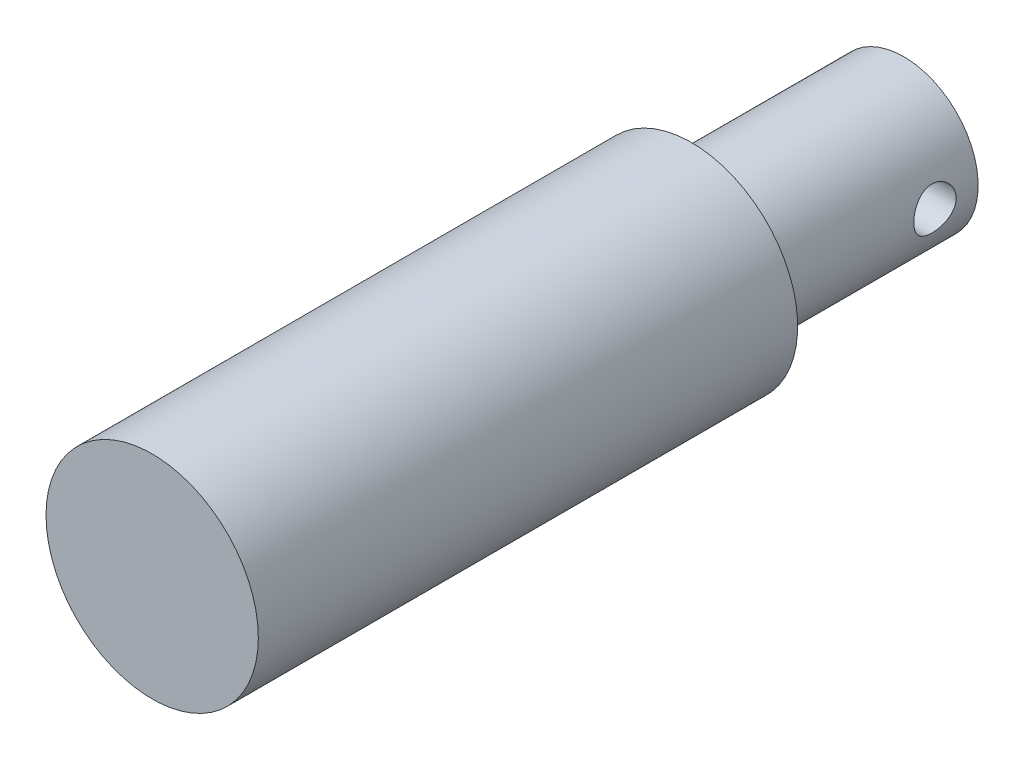
from build123d import *

# Parameters (mm, degrees)
SKETCH1_R               = 5
BOSS_EXTRUDE1_DEPTH     = 35.4
SKETCH2_R               = 1
CUT_EXTRUDE1_DEPTH      = 6
CUT_EXTRUDE1_DEPTH_BACK = 6
SKETCH3_OUTSIDE_W       = 19.624
SKETCH3_OUTSIDE_H       = 19.624
SKETCH3_OUTSIDE_R       = 3.5
CUT_EXTRUDE2_DEPTH      = 10


with BuildPart() as part:
    # Sketch1 → Boss-Extrude1 (new body)
    with BuildSketch(Plane.XY):
        Circle(SKETCH1_R)
    extrude(amount=BOSS_EXTRUDE1_DEPTH)

    # Sketch2 → Cut-Extrude1 (cut, two sides)
    with BuildSketch(Plane(origin=(0, 0, 0), x_dir=(0, 0, -1), z_dir=(1, 0, 0))) as cut_extrude1_sk:
        with Locations((-2.031417136, 0)):
            Circle(SKETCH2_R)
    extrude(amount=CUT_EXTRUDE1_DEPTH, mode=Mode.SUBTRACT)
    extrude(cut_extrude1_sk.sketch, amount=-CUT_EXTRUDE1_DEPTH_BACK, mode=Mode.SUBTRACT)

    # Sketch3 outside → Cut-Extrude2 (cut)
    with BuildSketch(Plane(origin=(0, 0, 0), x_dir=(-1, 0, 0), z_dir=(0, 0, -1))):
        Rectangle(SKETCH3_OUTSIDE_W, SKETCH3_OUTSIDE_H)
        Circle(SKETCH3_OUTSIDE_R, mode=Mode.SUBTRACT)
    extrude(amount=-CUT_EXTRUDE2_DEPTH, mode=Mode.SUBTRACT)


solid = part.part
